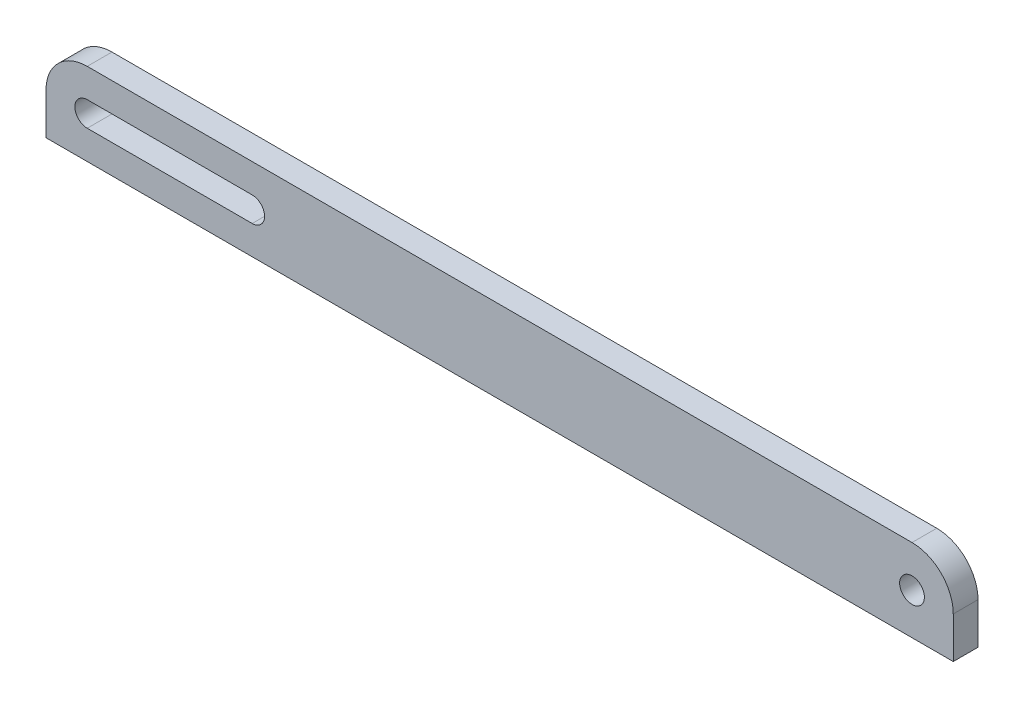
from build123d import *

# Parameters (mm, degrees)
SKETCH1_R           = 1.5
BOSS_EXTRUDE1_DEPTH = 3


with BuildPart() as part:
    # Sketch1 → Boss-Extrude1 (new body)
    with BuildSketch(Plane.XY):
        with BuildLine():
            Line((50, -5), (-50, -5))
            Line((-50, -5), (-55, -5))
            Line((-55, -5), (-55, 0))
            ThreePointArc((-55, 0), (-53.535533906, 3.535533906), (-50, 5))
            Line((-50, 5), (50, 5))
            ThreePointArc((50, 5), (53.535533906, 3.535533906), (55, 0))
            Line((55, 0), (55, -5))
            Line((55, -5), (50, -5))
        make_face()
        with Locations((50, 0)):
            Circle(SKETCH1_R, mode=Mode.SUBTRACT)
        with BuildLine():
            Line((-50, 1.5), (-30, 1.5))
            ThreePointArc((-30, 1.5), (-28.5, 0), (-30, -1.5))
            Line((-30, -1.5), (-50, -1.5))
            ThreePointArc((-50, -1.5), (-51.5, 0), (-50, 1.5))
        make_face(mode=Mode.SUBTRACT)
    extrude(amount=BOSS_EXTRUDE1_DEPTH)


solid = part.part
